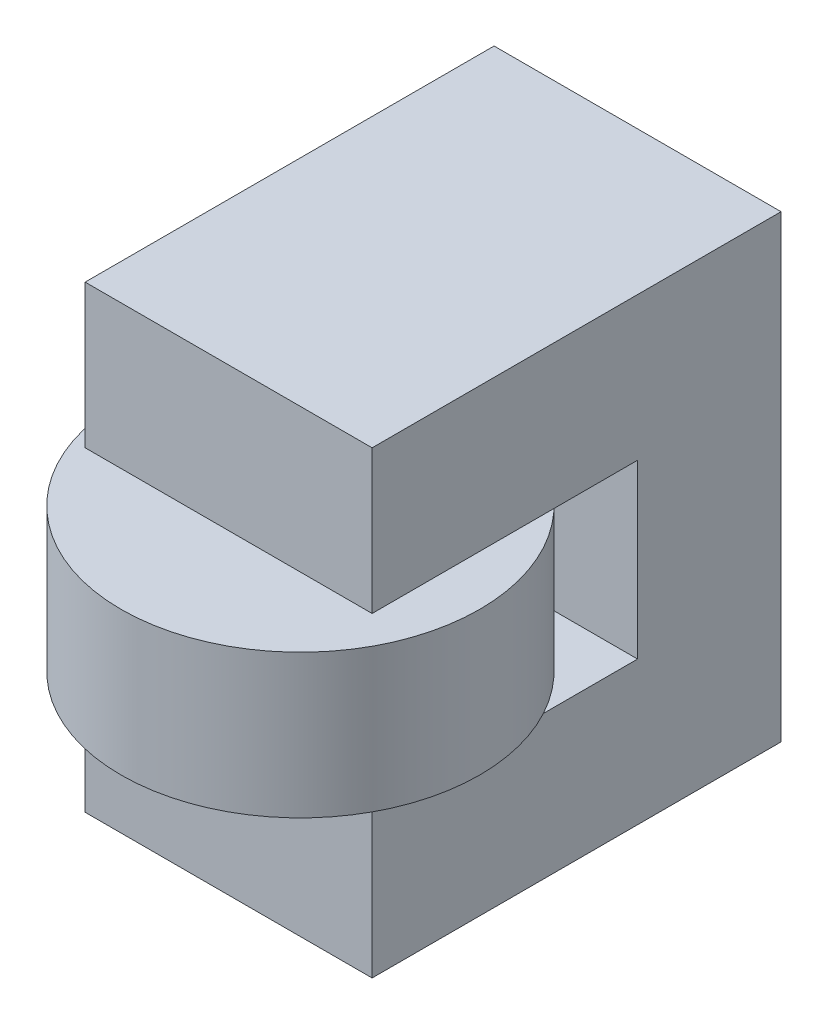
from build123d import *

# Parameters (mm, degrees)
SKETCH1_R                = 12.5
BOSS_EXTRUDE1_DEPTH      = 10
F_8_CLEARANCE_HOLE1_D    = 4.9149
BOSS_EXTRUDE2_DEPTH      = 10
BOSS_EXTRUDE2_DEPTH_BACK = 10


with BuildPart() as part:
    # Sketch1 → Boss-Extrude1 (new body)
    with BuildSketch(Plane(origin=(0, 0, 0), x_dir=(1, 0, 0), z_dir=(0, 1, 0))):
        Circle(SKETCH1_R)
    extrude(amount=BOSS_EXTRUDE1_DEPTH)

    # 8 Clearance Hole1 (through all)
    with Locations(Plane(origin=(0, 0, 0), x_dir=(-1, 0, 0), z_dir=(0, -1, 0))):
        with Locations((0, 0)):
            Hole(F_8_CLEARANCE_HOLE1_D / 2)


with BuildPart() as body_2:
    # Sketch4 → Boss-Extrude2 (new, two sides: drawn at the far end of the back side and taken through both)
    with BuildSketch(Plane(origin=(0, 0, 0), x_dir=(0, 0, -1), z_dir=(1, 0, 0)).offset(-BOSS_EXTRUDE2_DEPTH_BACK)):
        Polygon((-5, -1), (13.5, -1), (13.5, 11), (-5, 11), (-5, 21), (23.5, 21), (23.5, -11), (-5, -11), align=None)
    extrude(amount=BOSS_EXTRUDE2_DEPTH + BOSS_EXTRUDE2_DEPTH_BACK)


solid = Compound([part.part, body_2.part])
